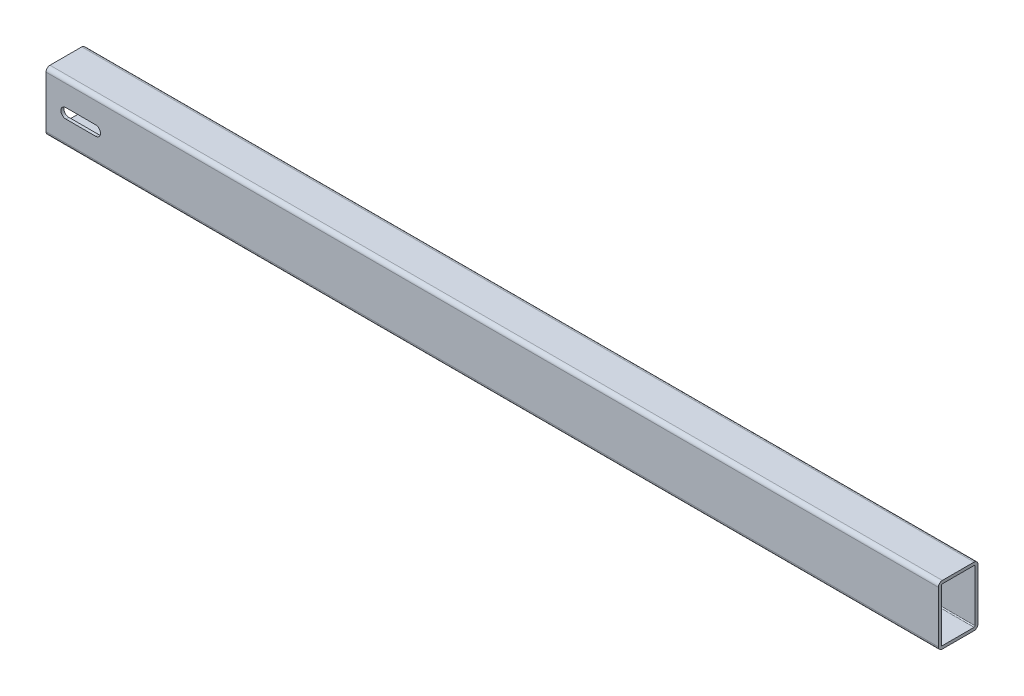
from build123d import *

# Parameters (mm, degrees)
EXTRUDE_1_DEPTH     = 900
CUT_EXTRUDE_1_DEPTH = 40


with BuildPart() as part:
    # Эскиз1 → Вытянуть-Тонкостенный1 (new body)
    with BuildSketch(Plane(origin=(0, 0, 0), x_dir=(0, 0, -1), z_dir=(1, 0, 0))):
        with BuildLine():
            Line((-3, 53), (-3, 1))
            ThreePointArc((-3, 1), (-1.828427125, -1.828427125), (1, -3))
            Line((1, -3), (33, -3))
            ThreePointArc((33, -3), (35.828427125, -1.828427125), (37, 1))
            Line((37, 1), (37, 53))
            ThreePointArc((37, 53), (35.828427125, 55.828427125), (33, 57))
            Line((33, 57), (1, 57))
            ThreePointArc((1, 57), (-1.828427125, 55.828427125), (-3, 53))
        make_face()
        with BuildLine():
            Line((0, 53), (0, 1))
            ThreePointArc((0, 1), (0.292893219, 0.292893219), (1, 0))
            Line((1, 0), (33, 0))
            ThreePointArc((33, 0), (33.707106781, 0.292893219), (34, 1))
            Line((34, 1), (34, 53))
            ThreePointArc((34, 53), (33.707106781, 53.707106781), (33, 54))
            Line((33, 54), (1, 54))
            ThreePointArc((1, 54), (0.292893219, 53.707106781), (0, 53))
        make_face(mode=Mode.SUBTRACT)
    extrude(amount=EXTRUDE_1_DEPTH)

    # Эскиз2 → Вырез-Вытянуть1 (cut)
    with BuildSketch(Plane.XY.offset(3)):
        with BuildLine():
            Line((20, 32), (50, 32))
            ThreePointArc((50, 32), (55, 27), (50, 22))
            Line((50, 22), (20, 22))
            ThreePointArc((20, 22), (15, 27), (20, 32))
        make_face()
    extrude(amount=-CUT_EXTRUDE_1_DEPTH, mode=Mode.SUBTRACT)


solid = part.part
